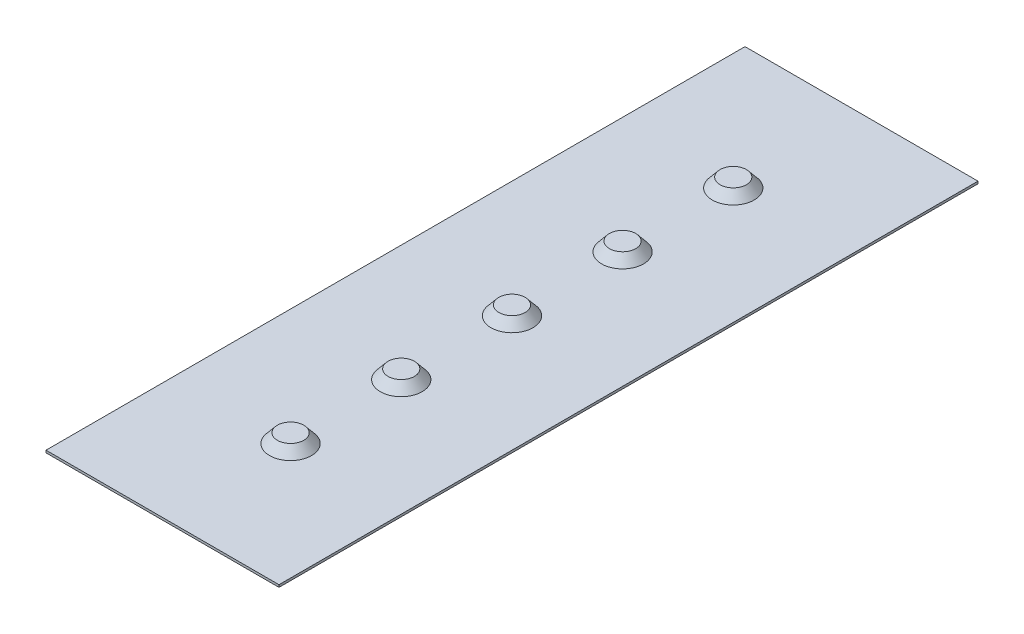
from build123d import *

# Parameters (mm, degrees)
SKETCH1_W           = 200
SKETCH1_H           = 600
BOSS_EXTRUDE1_DEPTH = 2
SKETCH3_R           = 18
BOSS_EXTRUDE2_DEPTH = 8
BOSS_EXTRUDE2_TAPER = 40


with BuildPart() as part:
    # Sketch1 → Boss-Extrude1 (new body)
    with BuildSketch(Plane(origin=(0, 0, 0), x_dir=(1, 0, 0), z_dir=(0, 1, 0))):
        with Locations((91.05572809, -273.16718427)):
            Rectangle(SKETCH1_W, SKETCH1_H)
    extrude(amount=BOSS_EXTRUDE1_DEPTH)

    # Sketch3 → Boss-Extrude2 (add)
    with BuildSketch(Plane(origin=(0, 2, 0), x_dir=(1, 0, 0), z_dir=(0, 1, 0))):
        with Locations((91.05572809, -83.246549225)):
            Circle(SKETCH3_R)
        with Locations((91.05572809, -178.246549225)):
            Circle(SKETCH3_R)
        with Locations((91.05572809, -273.16718427)):
            Circle(SKETCH3_R)
        with Locations((91.05572809, -368.246549225)):
            Circle(SKETCH3_R)
        with Locations((91.05572809, -463.246549225)):
            Circle(SKETCH3_R)
    extrude(amount=BOSS_EXTRUDE2_DEPTH, taper=BOSS_EXTRUDE2_TAPER)


solid = part.part
